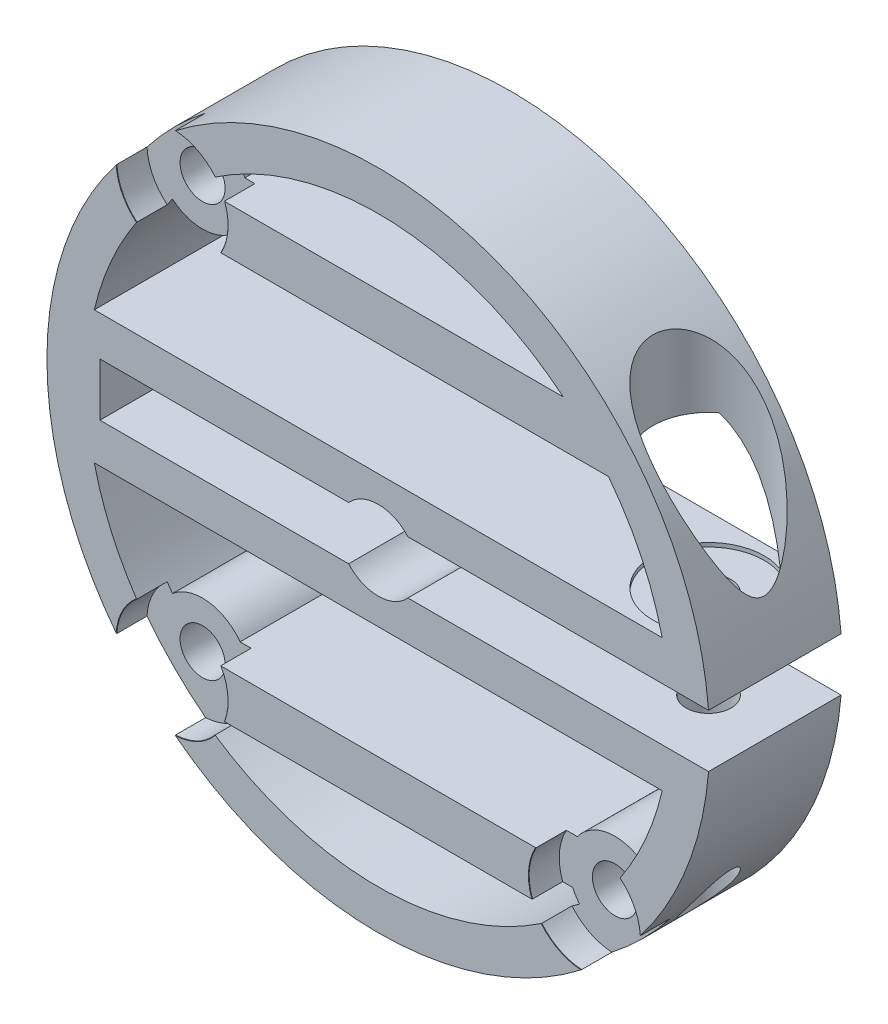
from build123d import *

# Parameters (mm, degrees)
BOSS_EXTRUDE1_DEPTH                           = 10
CBORE_FOR_M3_HEX_HEAD_MACHINE_SCREW3_AT_COUNT = 2
CBORE_FOR_M3_HEX_HEAD_MACHINE_SCREW3_AT_PITCH = 31.112698372
CBORE_FOR_M3_HEX_HEAD_MACHINE_SCREW3_2_COUNT  = 2
CBORE_FOR_M3_HEX_HEAD_MACHINE_SCREW3_2_PITCH  = 44
CUT_EXTRUDE1_START                            = -10
CUT_EXTRUDE1_DEPTH                            = 10


with BuildPart() as part:
    # Sketch1 → Boss-Extrude1 (new body)
    with BuildSketch(Plane.XY):
        with BuildLine():
            Line((-2.236067977, -2), (-21, -2))
            Line((-21, -2), (-21, 2))
            Line((-21, 2), (-2.236067977, 2))
            ThreePointArc((-2.236067977, 2), (0, 3), (2.236067977, 2))
            Line((2.236067977, 2), (24.919871589, 2))
            ThreePointArc((24.919871589, 2), (-25, 0), (24.919871589, -2))
            Line((24.919871589, -2), (2.236067977, -2))
            ThreePointArc((2.236067977, -2), (0, -3), (-2.236067977, -2))
        make_face()
    extrude(amount=BOSS_EXTRUDE1_DEPTH)

    # Sketch6 → CBORE for M3 Hex Head Machine Screw2 (revolve, cut)
    with BuildSketch(Plane(origin=(19.919871589, 22, 5), x_dir=(0, 0, 1), z_dir=(1, 0, 0))):
        Polygon((0, 0), (0, 47), (1.7, 47), (1.7, 17.3), (4.2, 17.3), (4.2, 0.025), (4.225, 0), align=None)
    revolve(axis=Axis((19.919871589, 28.35, 5), (0, -1, 0)), mode=Mode.SUBTRACT)

    # Sketch8 → CBORE for M3 Hex Head Machine Screw3 (revolve, cut)
    with BuildSketch(Plane(origin=(-15.556349186, 15.556349186, 10), x_dir=(0, -1, 0), z_dir=(1, 0, 0))):
        Polygon((0, 0), (0, 10), (1.7, 10), (1.7, 2.3), (4.2, 2.3), (4.2, 0.025), (4.225, 0), align=None)
    cbore_for_m3_hex_head_machine_screw3 = revolve(axis=Axis((-15.556349186, 15.556349186, 16.35), (0, 0, -1)), mode=Mode.SUBTRACT)

    # CBORE for M3 Hex Head Machine Screw3 at: CBORE for M3 Hex Head Machine Screw3 ×2
    with Locations(*[(0, -i * CBORE_FOR_M3_HEX_HEAD_MACHINE_SCREW3_AT_PITCH, 0) for i in range(1, CBORE_FOR_M3_HEX_HEAD_MACHINE_SCREW3_AT_COUNT)]):
        add(cbore_for_m3_hex_head_machine_screw3, mode=Mode.SUBTRACT)

    # CBORE for M3 Hex Head Machine Screw3 2: CBORE for M3 Hex Head Machine Screw3 ×2
    with Locations(*[Vector(0.707106781, -0.707106781, 0) * (i * CBORE_FOR_M3_HEX_HEAD_MACHINE_SCREW3_2_PITCH) for i in range(1, CBORE_FOR_M3_HEX_HEAD_MACHINE_SCREW3_2_COUNT)]):
        add(cbore_for_m3_hex_head_machine_screw3, mode=Mode.SUBTRACT)

    # Sketch9 → Cut-Extrude1 (cut)
    with BuildSketch(Plane(origin=(0, 0, 0), x_dir=(-1, 0, 0), z_dir=(0, 0, -1)).offset(CUT_EXTRUDE1_START)):
        with BuildLine():
            ThreePointArc((-17.370952766, 13.5), (-19.8577472, 9.46941794), (-21.424285286, 5))
            Line((-21.424285286, 5), (21.424285286, 5))
            ThreePointArc((21.424285286, 5), (20.018217875, 9.125291947), (17.826515683, 12.892452777))
            ThreePointArc((17.826515683, 12.892452777), (15.142522709, 12.080899913), (12.724136619, 13.5))
            Line((12.724136619, 13.5), (-17.370952766, 13.5))
        make_face()
        with BuildLine():
            Line((21.424285286, -5), (-21.424285286, -5))
            ThreePointArc((-21.424285286, -5), (-20.018217875, -9.125291947), (-17.826515683, -12.892452777))
            ThreePointArc((-17.826515683, -12.892452777), (-15.142522709, -12.080899913), (-12.724136619, -13.5))
            Line((-12.724136619, -13.5), (12.724136619, -13.5))
            ThreePointArc((12.724136619, -13.5), (15.142522709, -12.080899913), (17.826515683, -12.892452777))
            ThreePointArc((17.826515683, -12.892452777), (20.018217875, -9.125291947), (21.424285286, -5))
        make_face()
        with BuildLine():
            ThreePointArc((12.892452777, 17.826515683), (-0.676730397, 21.989589263), (-13.964240044, 17))
            Line((-13.964240044, 17), (12.367952673, 17))
            ThreePointArc((12.367952673, 17), (12.601164732, 17.431685114), (12.892452777, 17.826515683))
        make_face()
        with BuildLine():
            ThreePointArc((-12.367952673, -17), (-12.601164732, -17.431685114), (-12.892452777, -17.826515683))
            ThreePointArc((-12.892452777, -17.826515683), (0, -22), (12.892452777, -17.826515683))
            ThreePointArc((12.892452777, -17.826515683), (12.601164732, -17.431685114), (12.367952673, -17))
            Line((12.367952673, -17), (-12.367952673, -17))
        make_face()
    extrude(amount=CUT_EXTRUDE1_DEPTH, mode=Mode.SUBTRACT)


solid = part.part
